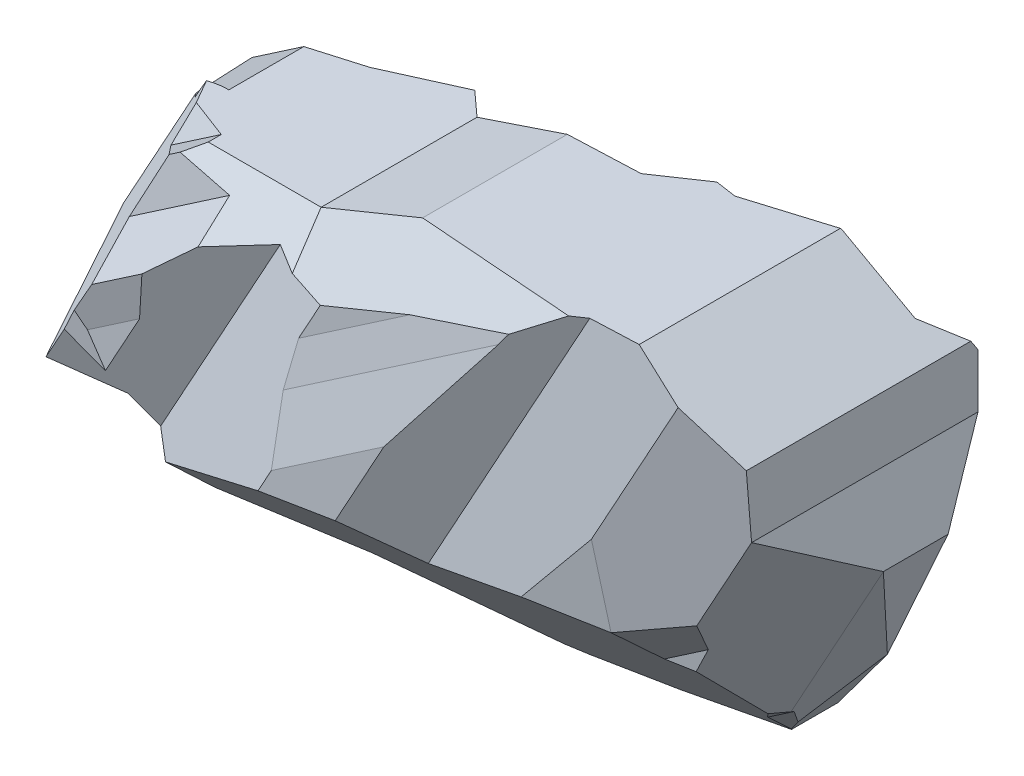
from build123d import *

# Parameters (mm, degrees)
BOSS_EXTRUDE1_DEPTH = 28.956
SKETCH2_OUTSIDE_W   = 104.225
SKETCH2_OUTSIDE_H   = 74.976
CUT_EXTRUDE1_DEPTH  = 28.956
CHAMFER1_SIZE       = 17.78
CHAMFER2_SIZE       = 7.62
CHAMFER3_SIZE       = 7.62
SKETCH3_OUTSIDE_W   = 109.871
SKETCH3_OUTSIDE_H   = 49.7
CUT_EXTRUDE2_DEPTH  = 60.198
SKETCH4_OUTSIDE_W   = 48.856
SKETCH4_OUTSIDE_H   = 100.249
CUT_EXTRUDE3_DEPTH  = 65.532


with BuildPart() as part:
    # Sketch1 → Boss-Extrude1 (new body)
    with BuildSketch(Plane.XY):
        with BuildLine():
            add(Edge.make_bspline(
                [(0, 26.329340351), (-15.786544799, 14.596384946), (-36.267616128, 18.74958365)],
                knots=[0, 0, 0, 1, 1, 1], degree=2))
            add(Edge.make_bspline(
                [(-36.267616128, 18.74958365), (-125.980614733, -26.329340351), (0, -26.329340351)],
                knots=[2.349082937, 2.349082937, 2.349082937, 4.702848639, 4.702848639, 4.702848639], degree=2, weights=[1, 0.374957632, 0.976740293]))
            add(Edge.make_bspline(
                [(0, -26.329340351), (0.906326781, -26.329340351), (1.812095783, -26.313136555)],
                knots=[4.702848639, 4.702848639, 4.702848639, 4.747474319, 4.747474319, 4.747474319], degree=2, weights=[0.976740293, 0.988149653, 1]))
            add(Edge.make_bspline(
                [(0, 26.329340351), (15.016751237, 25.038982394), (44.548809621, 18.28020699), (17.807382706, -25.169253325), (1.812095783, -26.313136555)],
                knots=[0, 0, 0, 0, 0.367872962, 0.976947038, 0.976947038, 0.976947038, 0.976947038], degree=3))
        make_face()
    extrude(amount=BOSS_EXTRUDE1_DEPTH)

    # Sketch2 outside → Cut-Extrude1 (cut)
    with BuildSketch(Plane.XY.offset(28.956)):
        with Locations((-10.7055, 0)):
            Rectangle(SKETCH2_OUTSIDE_W, SKETCH2_OUTSIDE_H)
        Polygon((-45.695007292, 8.912831724), (-42.621617043, 12.754569536), (-31.250073118, 12.754569536), (-23.259258469, 12.754569536), (-13.117070645, 16.903646374), (0, 19.055019548), (12.936005686, 21.176695674), (20.690222102, 16.903646374), (23.432684842, 15.392381036), (23.432684842, 8.912831724), (26.072382633, 2.460237124), (22.061453472, -8.912831724), (15.214644669, -17.471342729), (2.473177364, -21.20584876), (-6.558535322, -22.687169165), (-8.760365364, -22.687169165), (-19.88532873, -16.340644797), (-33.401446293, -16.340644797), (-38.472540205, -8.912831724), (-44.158312167, -6.907636041), (-51.519978603, -1.929165251), align=None, mode=Mode.SUBTRACT)
    extrude(amount=-CUT_EXTRUDE1_DEPTH, mode=Mode.SUBTRACT)

    # Chamfer1
    chamfer1_edges = [part.edges().sort_by_distance(p)[0] for p in [
        (-2.042678979, -21.946508963, 28.956),
    ]]
    chamfer(chamfer1_edges, length=CHAMFER1_SIZE)

    # Chamfer2
    chamfer2_edges = [part.edges().sort_by_distance(p)[0] for p in [
        (-18.188164557, 14.829107955, 28.956),
    ]]
    chamfer(chamfer2_edges, length=CHAMFER2_SIZE)

    # Chamfer3
    chamfer3_edges = [part.edges().sort_by_distance(p)[0] for p in [
        (-13.196740008, 12.754569536, 28.956),
    ]]
    chamfer(chamfer3_edges, length=CHAMFER3_SIZE)

    # Sketch3 outside → Cut-Extrude2 (cut)
    with BuildSketch(Plane(origin=(11.964634426, 21.711980874, 0), x_dir=(0.875823084, -0.482632289, 0), z_dir=(0.482632289, 0.875823084, 0))):
        with Locations((-10.7795, -14.478)):
            Rectangle(SKETCH3_OUTSIDE_W, SKETCH3_OUTSIDE_H)
        Polygon((-41.826185128, -14.74462757), (-38.497860604, -21.336), (-35.00576286, -28.251706873), (-26.526762563, -23.970221502), (-15.967663822, -28.251706873), (-9.823064699, -28.251706873), (-3.406709878, -25.011757782), (6.56253296, -26.631732327), (16.221265926, -25.011757782), (21.647404684, -14.478), (23.623550585, -10.068279635), (16.221265926, -2.384533072), (-1.82963065, -2.384533072), (-12.895364261, -7.972193753), (-26.526762563, -5.757129016), (-32.073003248, 0), (-38.436362681, -6.798953713), (-43.484763158, -6.798953713), (-42.326681299, -7.882839769), align=None, mode=Mode.SUBTRACT)
    extrude(amount=-CUT_EXTRUDE2_DEPTH, mode=Mode.SUBTRACT)

    # Sketch4 outside → Cut-Extrude3 (cut)
    with BuildSketch(Plane(origin=(-30.391792793, -20.748992187, 0), x_dir=(0, 0, 1), z_dir=(-0.825881698, -0.563843437, 0))):
        with Locations((14.126, 6.3845)):
            Rectangle(SKETCH4_OUTSIDE_W, SKETCH4_OUTSIDE_H)
        with BuildLine():
            Line((17.379043474, 33.940305121), (20.033797097, 30.011269758))
            Line((20.033797097, 30.011269758), (22.47617043, 30.011269758))
            Line((22.47617043, 30.011269758), (23.108500778, 26.340870516))
            Line((23.108500778, 26.340870516), (27.148536807, 23.108910338))
            Line((27.148536807, 23.108910338), (26.420684971, 19.743661409))
            Line((26.420684971, 19.743661409), (26.420684971, 15.955142831))
            Line((26.420684971, 15.955142831), (26.992031947, 12.638725208))
            Line((26.992031947, 12.638725208), (28.251706873, 7.392768888))
            Line((28.251706873, 7.392768888), (29.39802431, 2.618893435))
            Line((29.39802431, 2.618893435), (28.824865591, -0.031126348))
            Line((28.824865591, -0.031126348), (26.631732327, -2.772601154))
            Line((26.631732327, -2.772601154), (25.821745055, -9.959999212))
            Line((25.821745055, -9.959999212), (23.108500778, -13.351626593))
            Line((23.108500778, -13.351626593), (22.5757173, -18.07926499))
            Line((22.5757173, -18.07926499), (14.257053213, -21.384760387))
            Line((14.257053213, -21.384760387), (11.527022899, -24.797370761))
            Line((11.527022899, -24.797370761), (2.142356235, -22.767611))
            Line((2.142356235, -22.767611), (4.352503323, -18.07926499))
            Line((4.352503323, -18.07926499), (2.384533072, -14.418186985))
            Line((2.384533072, -14.418186985), (2.384533072, -11.501772175))
            Line((2.384533072, -11.501772175), (2.384533072, -1.401863751))
            Line((2.384533072, -1.401863751), (5.601070504, 2.618893435))
            Line((5.601070504, 2.618893435), (5.601070504, 10.015747048))
            Line((5.601070504, 10.015747048), (6.534511478, 14.331544691))
            Line((6.534511478, 14.331544691), (3.992801788, 18.093275032))
            Line((3.992801788, 18.093275032), (1.999794348, 23.108910338))
            Line((1.999794348, 23.108910338), (5.263656633, 27.188824848))
            Line((5.263656633, 27.188824848), (6.798953713, 29.107986959))
            Line((6.798953713, 29.107986959), (8.293414674, 31.975787439))
            Line((8.293414674, 31.975787439), (15.7861913, 31.975787439))
            ThreePointArc((15.7861913, 31.975787439), (16.234438667, 33.24035335), (17.379043474, 33.940305121))
        make_face(mode=Mode.SUBTRACT)
    extrude(amount=-CUT_EXTRUDE3_DEPTH, mode=Mode.SUBTRACT)


solid = part.part
